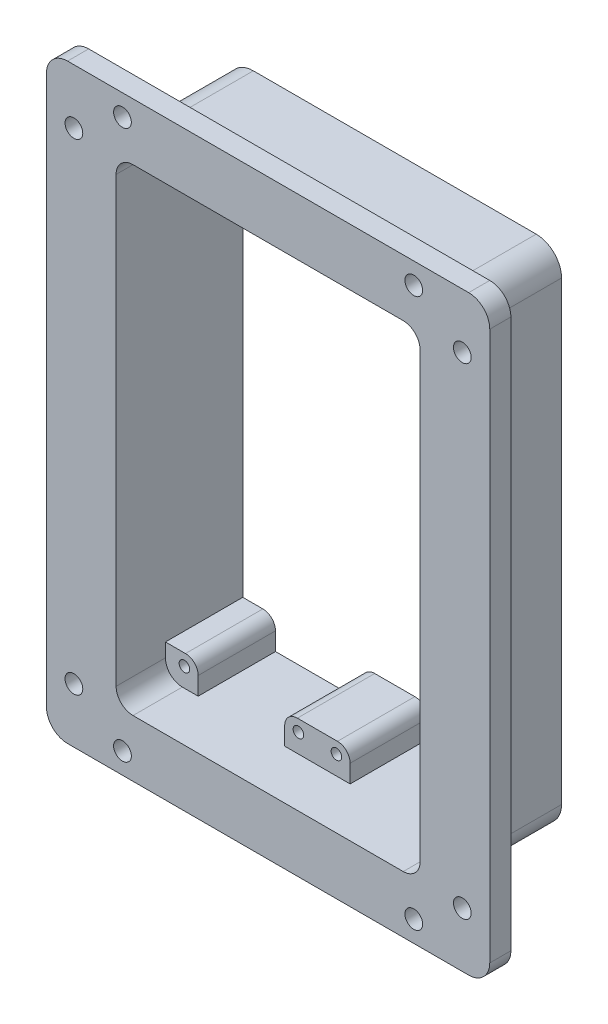
from build123d import *

# Parameters (mm, degrees)
BOSS_EXTRUDE1_DEPTH = 5
BOSS_EXTRUDE2_DEPTH = 25
CUT_EXTRUDE1_REACH  = 32
SKETCH4_R           = 2.1
CUT_EXTRUDE2_REACH  = 27
BOSS_EXTRUDE4_DEPTH = 18.32
SKETCH9_R           = 1.25
CUT_EXTRUDE3_DEPTH  = 10
CUT_EXTRUDE4_REACH  = 32
SKETCH10_R          = 2.1


with BuildPart() as part:
    # Sketch1 → Boss-Extrude1 (new body)
    with BuildSketch(Plane.XY):
        with BuildLine():
            Line((-47.5, 70), (47.5, 70))
            ThreePointArc((47.5, 70), (51.035533906, 68.535533906), (52.5, 65))
            Line((52.5, 65), (52.5, -65))
            ThreePointArc((52.5, -65), (51.035533906, -68.535533906), (47.5, -70))
            Line((47.5, -70), (-47.5, -70))
            ThreePointArc((-47.5, -70), (-51.035533906, -68.535533906), (-52.5, -65))
            Line((-52.5, -65), (-52.5, 65))
            ThreePointArc((-52.5, 65), (-51.035533906, 68.535533906), (-47.5, 70))
        make_face()
        with BuildLine():
            Line((-32, 56.5), (32, 56.5))
            ThreePointArc((32, 56.5), (34.828427125, 55.328427125), (36, 52.5))
            Line((36, 52.5), (36, -52.5))
            ThreePointArc((36, -52.5), (34.828427125, -55.328427125), (32, -56.5))
            Line((32, -56.5), (-32, -56.5))
            ThreePointArc((-32, -56.5), (-34.828427125, -55.328427125), (-36, -52.5))
            Line((-36, -52.5), (-36, 52.5))
            ThreePointArc((-36, 52.5), (-34.828427125, 55.328427125), (-32, 56.5))
        make_face(mode=Mode.SUBTRACT)
    extrude(amount=BOSS_EXTRUDE1_DEPTH)

    # Sketch2 → Boss-Extrude2 (add)
    with BuildSketch(Plane(origin=(0, 0, 0), x_dir=(-1, 0, 0), z_dir=(0, 0, -1))):
        with BuildLine():
            Line((-33.5, 60), (33.5, 60))
            ThreePointArc((33.5, 60), (37.742640687, 58.242640687), (39.5, 54))
            Line((39.5, 54), (39.5, -54))
            ThreePointArc((39.5, -54), (37.742640687, -58.242640687), (33.5, -60))
            Line((33.5, -60), (-33.5, -60))
            ThreePointArc((-33.5, -60), (-37.742640687, -58.242640687), (-39.5, -54))
            Line((-39.5, -54), (-39.5, 54))
            ThreePointArc((-39.5, 54), (-37.742640687, 58.242640687), (-33.5, 60))
        make_face()
    extrude(amount=BOSS_EXTRUDE2_DEPTH)

    # Sketch4 → Cut-Extrude1 (cut, up to next)
    with BuildSketch(Plane.XY.offset(5), mode=Mode.PRIVATE) as cut_extrude1_sk1:
        with Locations((34.5, 65)):
            Circle(SKETCH4_R)
    cut_extrude1_tool1 = extrude(cut_extrude1_sk1.sketch, amount=-CUT_EXTRUDE1_REACH, mode=Mode.PRIVATE) & part.part
    add(cut_extrude1_tool1.solids().sort_by_distance((34.5, 65, 5))[0], mode=Mode.SUBTRACT)
    # Sketch4 → Cut-Extrude1 (cut, up to next)
    with BuildSketch(Plane.XY.offset(5), mode=Mode.PRIVATE) as cut_extrude1_sk2:
        with Locations((-34.5, 65)):
            Circle(SKETCH4_R)
    cut_extrude1_tool2 = extrude(cut_extrude1_sk2.sketch, amount=-CUT_EXTRUDE1_REACH, mode=Mode.PRIVATE) & part.part
    add(cut_extrude1_tool2.solids().sort_by_distance((-34.5, 65, 5))[0], mode=Mode.SUBTRACT)
    # Sketch4 → Cut-Extrude1 (cut, up to next)
    with BuildSketch(Plane.XY.offset(5), mode=Mode.PRIVATE) as cut_extrude1_sk3:
        with Locations((-34.5, -65)):
            Circle(SKETCH4_R)
    cut_extrude1_tool3 = extrude(cut_extrude1_sk3.sketch, amount=-CUT_EXTRUDE1_REACH, mode=Mode.PRIVATE) & part.part
    add(cut_extrude1_tool3.solids().sort_by_distance((-34.5, -65, 5))[0], mode=Mode.SUBTRACT)
    # Sketch4 → Cut-Extrude1 (cut, up to next)
    with BuildSketch(Plane.XY.offset(5), mode=Mode.PRIVATE) as cut_extrude1_sk4:
        with Locations((34.5, -65)):
            Circle(SKETCH4_R)
    cut_extrude1_tool4 = extrude(cut_extrude1_sk4.sketch, amount=-CUT_EXTRUDE1_REACH, mode=Mode.PRIVATE) & part.part
    add(cut_extrude1_tool4.solids().sort_by_distance((34.5, -65, 5))[0], mode=Mode.SUBTRACT)

    # Sketch5 → Cut-Extrude2 (cut, up to next)
    with BuildSketch(Plane.XY, mode=Mode.PRIVATE) as cut_extrude2_sk1:
        with BuildLine():
            Line((-32, 56.5), (32, 56.5))
            ThreePointArc((32, 56.5), (34.828427125, 55.328427125), (36, 52.5))
            Line((36, 52.5), (36, -52.5))
            ThreePointArc((36, -52.5), (34.828427125, -55.328427125), (32, -56.5))
            Line((32, -56.5), (-32, -56.5))
            ThreePointArc((-32, -56.5), (-34.828427125, -55.328427125), (-36, -52.5))
            Line((-36, -52.5), (-36, 52.5))
            ThreePointArc((-36, 52.5), (-34.828427125, 55.328427125), (-32, 56.5))
        make_face()
    cut_extrude2_tool1 = extrude(cut_extrude2_sk1.sketch, amount=-CUT_EXTRUDE2_REACH, mode=Mode.PRIVATE) & part.part
    add(cut_extrude2_tool1.solids().sort_by_distance((0, 0, 0))[0], mode=Mode.SUBTRACT)

    # Sketch8 → Boss-Extrude4 (add)
    with BuildSketch(Plane(origin=(0, 0, -25), x_dir=(-1, 0, 0), z_dir=(0, 0, -1))):
        with BuildLine():
            Line((-28.25, 52.25), (-28.25, 56.5))
            Line((-28.25, 56.5), (-32, 56.5))
            ThreePointArc((-32, 56.5), (-34.828427125, 55.328427125), (-36, 52.5))
            Line((-36, 52.5), (-36, 49.25))
            Line((-36, 49.25), (-31.25, 49.25))
            ThreePointArc((-31.25, 49.25), (-29.128679656, 50.128679656), (-28.25, 52.25))
        make_face()
        with BuildLine():
            Line((0, 49.25), (0, 56.5))
            Line((0, 56.5), (-7.75, 56.5))
            Line((-7.75, 56.5), (-7.75, 52.25))
            ThreePointArc((-7.75, 52.25), (-6.871320344, 50.128679656), (-4.75, 49.25))
            Line((-4.75, 49.25), (0, 49.25))
        make_face()
        with BuildLine():
            Line((7.75, 52.25), (7.75, 56.5))
            Line((7.75, 56.5), (0, 56.5))
            Line((0, 56.5), (0, 49.25))
            Line((0, 49.25), (4.75, 49.25))
            ThreePointArc((4.75, 49.25), (6.871320344, 50.128679656), (7.75, 52.25))
        make_face()
        with BuildLine():
            Line((28.25, 56.5), (28.25, 52.25))
            ThreePointArc((28.25, 52.25), (29.128679656, 50.128679656), (31.25, 49.25))
            Line((31.25, 49.25), (36, 49.25))
            Line((36, 49.25), (36, 52.5))
            ThreePointArc((36, 52.5), (34.828427125, 55.328427125), (32, 56.5))
            Line((32, 56.5), (28.25, 56.5))
        make_face()
        with BuildLine():
            Line((-31.25, -49.25), (-36, -49.25))
            Line((-36, -49.25), (-36, -52.5))
            ThreePointArc((-36, -52.5), (-34.828427125, -55.328427125), (-32, -56.5))
            Line((-32, -56.5), (-28.25, -56.5))
            Line((-28.25, -56.5), (-28.25, -52.25))
            ThreePointArc((-28.25, -52.25), (-29.128679656, -50.128679656), (-31.25, -49.25))
        make_face()
        with BuildLine():
            Line((-7.75, -56.5), (0, -56.5))
            Line((0, -56.5), (0, -49.25))
            Line((0, -49.25), (-4.75, -49.25))
            ThreePointArc((-4.75, -49.25), (-6.871320344, -50.128679656), (-7.75, -52.25))
            Line((-7.75, -52.25), (-7.75, -56.5))
        make_face()
        with BuildLine():
            Line((0, -56.5), (7.75, -56.5))
            Line((7.75, -56.5), (7.75, -52.25))
            ThreePointArc((7.75, -52.25), (6.871320344, -50.128679656), (4.75, -49.25))
            Line((4.75, -49.25), (0, -49.25))
            Line((0, -49.25), (0, -56.5))
        make_face()
        with BuildLine():
            Line((36, -52.5), (36, -49.25))
            Line((36, -49.25), (31.25, -49.25))
            ThreePointArc((31.25, -49.25), (29.128679656, -50.128679656), (28.25, -52.25))
            Line((28.25, -52.25), (28.25, -56.5))
            Line((28.25, -56.5), (32, -56.5))
            ThreePointArc((32, -56.5), (34.828427125, -55.328427125), (36, -52.5))
        make_face()
    extrude(amount=-BOSS_EXTRUDE4_DEPTH)

    # Sketch9 → Cut-Extrude3 (cut)
    with BuildSketch(Plane.XY.offset(-6.68)):
        with Locations((-4.5, 52)):
            Circle(SKETCH9_R)
        with Locations((-31.5, 52)):
            Circle(SKETCH9_R)
        with Locations((31.5, 52)):
            Circle(SKETCH9_R)
        with Locations((4.5, 52)):
            Circle(SKETCH9_R)
        with Locations((4.5, -52)):
            Circle(SKETCH9_R)
        with Locations((31.5, -52)):
            Circle(SKETCH9_R)
        with Locations((-31.5, -52)):
            Circle(SKETCH9_R)
        with Locations((-4.5, -52)):
            Circle(SKETCH9_R)
    extrude(amount=-CUT_EXTRUDE3_DEPTH, mode=Mode.SUBTRACT)

    # Sketch10 → Cut-Extrude4 (cut, up to next)
    with BuildSketch(Plane.XY.offset(5), mode=Mode.PRIVATE) as cut_extrude4_sk1:
        with Locations((-46, 57)):
            Circle(SKETCH10_R)
    cut_extrude4_tool1 = extrude(cut_extrude4_sk1.sketch, amount=-CUT_EXTRUDE4_REACH, mode=Mode.PRIVATE) & part.part
    add(cut_extrude4_tool1.solids().sort_by_distance((-46, 57, 5))[0], mode=Mode.SUBTRACT)
    # Sketch10 → Cut-Extrude4 (cut, up to next)
    with BuildSketch(Plane.XY.offset(5), mode=Mode.PRIVATE) as cut_extrude4_sk2:
        with Locations((46, 57)):
            Circle(SKETCH10_R)
    cut_extrude4_tool2 = extrude(cut_extrude4_sk2.sketch, amount=-CUT_EXTRUDE4_REACH, mode=Mode.PRIVATE) & part.part
    add(cut_extrude4_tool2.solids().sort_by_distance((46, 57, 5))[0], mode=Mode.SUBTRACT)
    # Sketch10 → Cut-Extrude4 (cut, up to next)
    with BuildSketch(Plane.XY.offset(5), mode=Mode.PRIVATE) as cut_extrude4_sk3:
        with Locations((46, -57)):
            Circle(SKETCH10_R)
    cut_extrude4_tool3 = extrude(cut_extrude4_sk3.sketch, amount=-CUT_EXTRUDE4_REACH, mode=Mode.PRIVATE) & part.part
    add(cut_extrude4_tool3.solids().sort_by_distance((46, -57, 5))[0], mode=Mode.SUBTRACT)
    # Sketch10 → Cut-Extrude4 (cut, up to next)
    with BuildSketch(Plane.XY.offset(5), mode=Mode.PRIVATE) as cut_extrude4_sk4:
        with Locations((-46, -57)):
            Circle(SKETCH10_R)
    cut_extrude4_tool4 = extrude(cut_extrude4_sk4.sketch, amount=-CUT_EXTRUDE4_REACH, mode=Mode.PRIVATE) & part.part
    add(cut_extrude4_tool4.solids().sort_by_distance((-46, -57, 5))[0], mode=Mode.SUBTRACT)


solid = part.part
